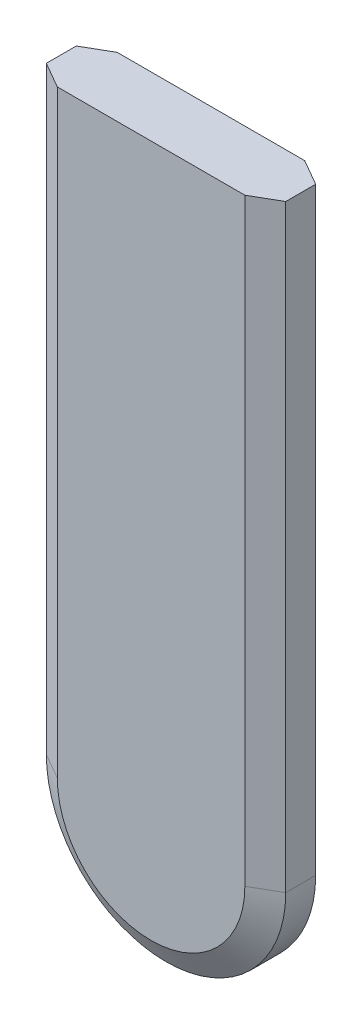
from build123d import *
from OCP.BRepFilletAPI import BRepFilletAPI_MakeChamfer

# Parameters (mm, degrees)
BOSS_EXTRUDE1_DEPTH = 6.35
CHAMFER1_SIZE       = 1.5875
CHAMFER1_SIZE2      = 2.749630657
CHAMFER2_SIZE       = 1.5875
CHAMFER2_SIZE2      = 2.749630657


with BuildPart() as part:
    # Sketch1 → Boss-Extrude1 (new body)
    with BuildSketch(Plane.XY):
        with BuildLine():
            Line((0, 0), (0, -63.5))
            ThreePointArc((0, -63.5), (12.7, -76.2), (25.4, -63.5))
            Line((25.4, -63.5), (25.4, 0))
            Line((25.4, 0), (0, 0))
        make_face()
    extrude(amount=BOSS_EXTRUDE1_DEPTH)

    # Chamfer1: one chamfer whose edges measure the first distance from different faces: ONE call of the kernel's chamfer builder (chamfer() names one face for all edges)
    chamfer1_edges_1 = [part.edges().sort_by_distance(p)[0] for p in [
        (12.7, -76.2, 6.35),
    ]]
    chamfer1_side_1 = [part.faces().sort_by_distance(p)[0] for p in [
        (12.7, -76.2, 3.175),
    ]]
    chamfer1_edges_2 = [part.edges().sort_by_distance(p)[0] for p in [
        (25.4, -31.75, 6.35),
    ]]
    chamfer1_side_2 = [part.faces().sort_by_distance(p)[0] for p in [
        (25.4, -31.75, 3.175),
    ]]
    chamfer1_edges_3 = [part.edges().sort_by_distance(p)[0] for p in [
        (0, -31.75, 6.35),
    ]]
    chamfer1_side_3 = [part.faces().sort_by_distance(p)[0] for p in [
        (0, -31.75, 3.175),
    ]]
    chamfer1 = BRepFilletAPI_MakeChamfer(part.part.solid().wrapped)
    for e in chamfer1_edges_1:
        chamfer1.Add(CHAMFER1_SIZE, CHAMFER1_SIZE2, e.wrapped, chamfer1_side_1[0].wrapped)  # the first distance lies on this face
    for e in chamfer1_edges_2:
        chamfer1.Add(CHAMFER1_SIZE, CHAMFER1_SIZE2, e.wrapped, chamfer1_side_2[0].wrapped)  # the first distance lies on this face
    for e in chamfer1_edges_3:
        chamfer1.Add(CHAMFER1_SIZE, CHAMFER1_SIZE2, e.wrapped, chamfer1_side_3[0].wrapped)  # the first distance lies on this face
    add(Compound.cast(chamfer1.Shape()), mode=Mode.REPLACE)

    # Chamfer2: one chamfer whose edges measure the first distance from different faces: ONE call of the kernel's chamfer builder (chamfer() names one face for all edges)
    chamfer2_edges_1 = [part.edges().sort_by_distance(p)[0] for p in [
        (25.4, -31.75, 0),
    ]]
    chamfer2_side_1 = [part.faces().sort_by_distance(p)[0] for p in [
        (25.4, -31.75, 2.38125),
    ]]
    chamfer2_edges_2 = [part.edges().sort_by_distance(p)[0] for p in [
        (12.7, -76.2, 0),
    ]]
    chamfer2_side_2 = [part.faces().sort_by_distance(p)[0] for p in [
        (12.7, -76.2, 2.38125),
    ]]
    chamfer2_edges_3 = [part.edges().sort_by_distance(p)[0] for p in [
        (0, -31.75, 0),
    ]]
    chamfer2_side_3 = [part.faces().sort_by_distance(p)[0] for p in [
        (0, -31.75, 2.38125),
    ]]
    chamfer2 = BRepFilletAPI_MakeChamfer(part.part.solid().wrapped)
    for e in chamfer2_edges_1:
        chamfer2.Add(CHAMFER2_SIZE, CHAMFER2_SIZE2, e.wrapped, chamfer2_side_1[0].wrapped)  # the first distance lies on this face
    for e in chamfer2_edges_2:
        chamfer2.Add(CHAMFER2_SIZE, CHAMFER2_SIZE2, e.wrapped, chamfer2_side_2[0].wrapped)  # the first distance lies on this face
    for e in chamfer2_edges_3:
        chamfer2.Add(CHAMFER2_SIZE, CHAMFER2_SIZE2, e.wrapped, chamfer2_side_3[0].wrapped)  # the first distance lies on this face
    add(Compound.cast(chamfer2.Shape()), mode=Mode.REPLACE)


solid = part.part
